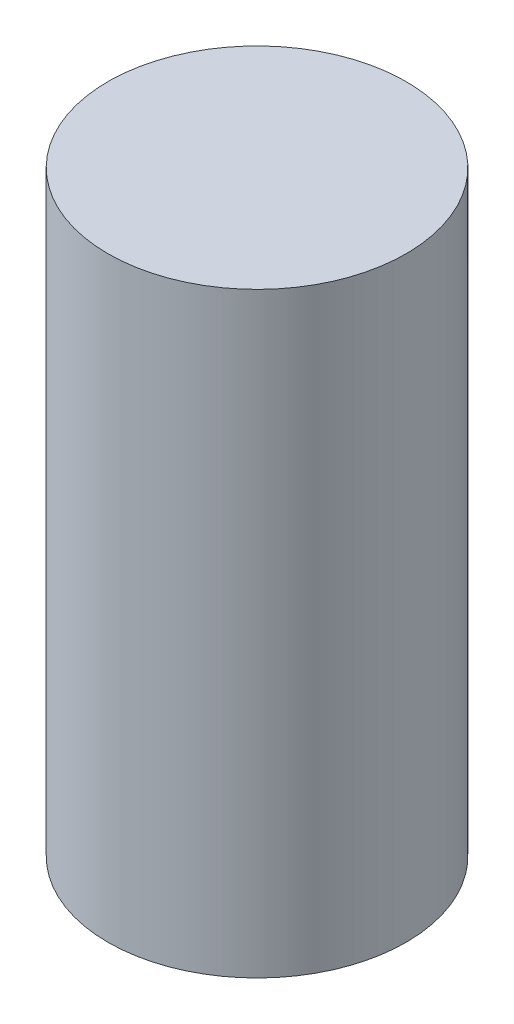
from build123d import *

# Parameters (mm, degrees)
SKETCH1_R           = 1.25
BOSS_EXTRUDE1_DEPTH = 5


with BuildPart() as part:
    # Sketch1 → Boss-Extrude1 (new body)
    with BuildSketch(Plane(origin=(0, 0, 0), x_dir=(1, 0, 0), z_dir=(0, 1, 0))):
        Circle(SKETCH1_R)
    extrude(amount=BOSS_EXTRUDE1_DEPTH)


solid = part.part
